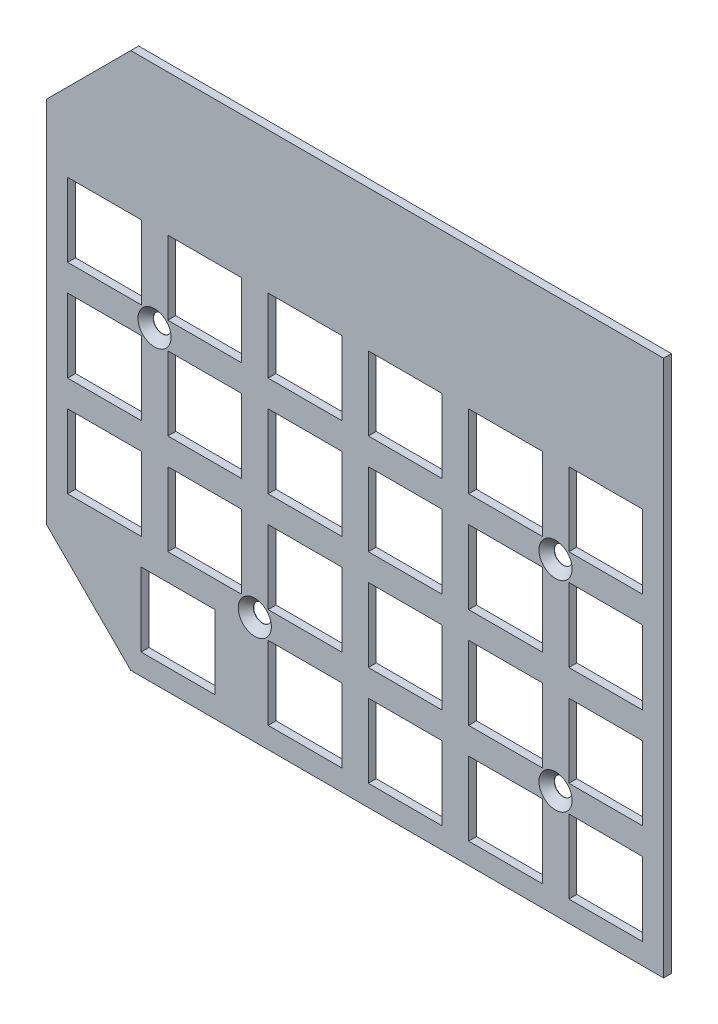
from build123d import *

# Parameters (mm, degrees)
BOSS_EXTRU_1_DEPTH                          = 1.5
ESQUISSE2_W                                 = 14
ESQUISSE2_H                                 = 14
ENL_V_MAT_EXTRU_1_DEPTH                     = 1.5
FRAISAGE_POUR_VIS_T_TE_FRAIS_E_M31_AT_COUNT = 2
FRAISAGE_POUR_VIS_T_TE_FRAIS_E_M31_AT_PITCH = 76.2
FRAISAGE_POUR_VIS_T_TE_FRAIS_E_M31_2_COUNT  = 2
FRAISAGE_POUR_VIS_T_TE_FRAIS_E_M31_2_PITCH  = 85.194189943
FRAISAGE_POUR_VIS_T_TE_FRAIS_E_M31_3_COUNT  = 2
FRAISAGE_POUR_VIS_T_TE_FRAIS_E_M31_3_PITCH  = 42.597094971


with BuildPart() as part:
    # Esquisse1 → Boss.-Extru.1 (new body)
    with BuildSketch(Plane.XY):
        Polygon((0, -85), (16, -101), (117.25, -101), (117.25, 1), (16, 1), (0, -15), align=None)
    extrude(amount=BOSS_EXTRU_1_DEPTH)

    # Esquisse2 → Enlèv. mat.-Extru.1 (cut)
    with BuildSketch(Plane.XY.offset(1.5)):
        with Locations((11, -32.85)):
            Rectangle(ESQUISSE2_W, ESQUISSE2_H)
        with Locations((30.05, -32.85)):
            Rectangle(ESQUISSE2_W, ESQUISSE2_H)
        with Locations((49.1, -32.85)):
            Rectangle(ESQUISSE2_W, ESQUISSE2_H)
        with Locations((68.15, -32.85)):
            Rectangle(ESQUISSE2_W, ESQUISSE2_H)
        with Locations((87.2, -32.85)):
            Rectangle(ESQUISSE2_W, ESQUISSE2_H)
        with Locations((106.25, -32.85)):
            Rectangle(ESQUISSE2_W, ESQUISSE2_H)
        with Locations((30.05, -51.9)):
            Rectangle(ESQUISSE2_W, ESQUISSE2_H)
        with Locations((49.1, -51.9)):
            Rectangle(ESQUISSE2_W, ESQUISSE2_H)
        with Locations((68.15, -51.9)):
            Rectangle(ESQUISSE2_W, ESQUISSE2_H)
        with Locations((87.2, -51.9)):
            Rectangle(ESQUISSE2_W, ESQUISSE2_H)
        with Locations((106.25, -51.9)):
            Rectangle(ESQUISSE2_W, ESQUISSE2_H)
        with Locations((30.05, -70.95)):
            Rectangle(ESQUISSE2_W, ESQUISSE2_H)
        with Locations((49.1, -70.95)):
            Rectangle(ESQUISSE2_W, ESQUISSE2_H)
        with Locations((68.15, -70.95)):
            Rectangle(ESQUISSE2_W, ESQUISSE2_H)
        with Locations((87.2, -70.95)):
            Rectangle(ESQUISSE2_W, ESQUISSE2_H)
        with Locations((106.25, -70.95)):
            Rectangle(ESQUISSE2_W, ESQUISSE2_H)
        with Locations((11, -51.9)):
            Rectangle(ESQUISSE2_W, ESQUISSE2_H)
        with Locations((11, -70.95)):
            Rectangle(ESQUISSE2_W, ESQUISSE2_H)
        with Locations((49.1, -90)):
            Rectangle(ESQUISSE2_W, ESQUISSE2_H)
        with Locations((68.15, -90)):
            Rectangle(ESQUISSE2_W, ESQUISSE2_H)
        with Locations((87.2, -90)):
            Rectangle(ESQUISSE2_W, ESQUISSE2_H)
        with Locations((106.25, -90)):
            Rectangle(ESQUISSE2_W, ESQUISSE2_H)
        with Locations((24.97, -90)):
            Rectangle(ESQUISSE2_W, ESQUISSE2_H)
    extrude(amount=-ENL_V_MAT_EXTRU_1_DEPTH, mode=Mode.SUBTRACT)

    # Esquisse18 → Fraisage pour vis à tête fraisée M31 (revolve, cut)
    with BuildSketch(Plane(origin=(20.525, -42.375, 1.5), x_dir=(0, -1, 0), z_dir=(1, 0, 0))):
        Polygon((0, 0), (0, 1.5), (1.7, 1.5), (1.7, 1.45), (3.15, 0), align=None)
    fraisage_pour_vis_t_te_frais_e_m31 = revolve(axis=Axis((20.525, -42.375, 7.85), (0, 0, -1)), mode=Mode.SUBTRACT)

    # Fraisage pour vis à tête fraisée M31 at: Fraisage pour vis à tête fraisée M31 ×2
    with Locations(*[(i * FRAISAGE_POUR_VIS_T_TE_FRAIS_E_M31_AT_PITCH, 0, 0) for i in range(1, FRAISAGE_POUR_VIS_T_TE_FRAIS_E_M31_AT_COUNT)]):
        add(fraisage_pour_vis_t_te_frais_e_m31, mode=Mode.SUBTRACT)

    # Fraisage pour vis _ t_te frais_e M31 2: Fraisage pour vis à tête fraisée M31 ×2
    with Locations(*[Vector(0.894427191, -0.447213595, 0) * (i * FRAISAGE_POUR_VIS_T_TE_FRAIS_E_M31_2_PITCH) for i in range(1, FRAISAGE_POUR_VIS_T_TE_FRAIS_E_M31_2_COUNT)]):
        add(fraisage_pour_vis_t_te_frais_e_m31, mode=Mode.SUBTRACT)

    # Fraisage pour vis _ t_te frais_e M31 3: Fraisage pour vis à tête fraisée M31 ×2
    with Locations(*[Vector(0.447213596, -0.894427191, 0) * (i * FRAISAGE_POUR_VIS_T_TE_FRAIS_E_M31_3_PITCH) for i in range(1, FRAISAGE_POUR_VIS_T_TE_FRAIS_E_M31_3_COUNT)]):
        add(fraisage_pour_vis_t_te_frais_e_m31, mode=Mode.SUBTRACT)


solid = part.part
